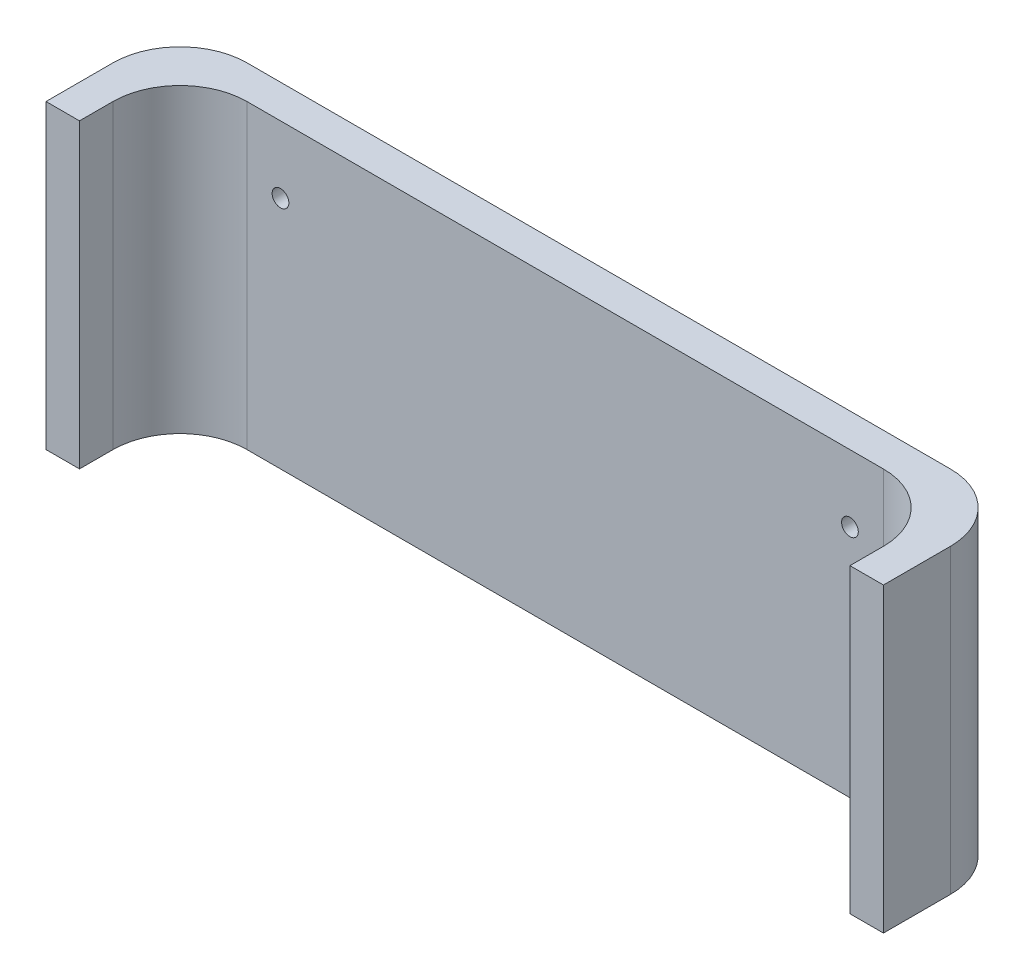
from build123d import *

# Parameters (mm, degrees)
SKETCH1_W           = 250
SKETCH1_H           = 250
SKETCH1_W_2         = 230
SKETCH1_H_2         = 230
BOSS_EXTRUDE1_DEPTH = 90
SKETCH2_W           = 200
SKETCH2_H           = 70
CUT_EXTRUDE1_DEPTH  = 50
FILLET1_R           = 20
SKETCH3_W           = 210
SKETCH3_H           = 90
CUT_EXTRUDE2_DEPTH  = 251
SKETCH4_R           = 2.5
CUT_EXTRUDE3_DEPTH  = 10


with BuildPart() as part:
    # Sketch1 → Boss-Extrude1 (new body)
    with BuildSketch(Plane(origin=(0, 0, 0), x_dir=(1, 0, 0), z_dir=(0, 1, 0))):
        Rectangle(SKETCH1_W, SKETCH1_H)
        Rectangle(SKETCH1_W_2, SKETCH1_H_2, mode=Mode.SUBTRACT)
    extrude(amount=BOSS_EXTRUDE1_DEPTH)

    # Sketch2 → Cut-Extrude1 (cut)
    with BuildSketch(Plane.XY.offset(125)):
        with Locations((0, 35)):
            Rectangle(SKETCH2_W, SKETCH2_H)
    extrude(amount=-CUT_EXTRUDE1_DEPTH, mode=Mode.SUBTRACT)

    # Fillet1
    fillet1_edges = [part.edges().sort_by_distance(p)[0] for p in [
        (-115, 45, 115),
        (115, 45, 115),
        (115, 45, -115),
        (-115, 45, -115),
        (-125, 45, 125),
        (125, 45, 125),
        (125, 45, -125),
        (-125, 45, -125),
    ]]
    fillet(fillet1_edges, radius=FILLET1_R)

    # Sketch3 → Cut-Extrude2 (cut, through all)
    with BuildSketch(Plane.ZY.offset(125)):
        with Locations((20, 45)):
            Rectangle(SKETCH3_W, SKETCH3_H)
    extrude(amount=-CUT_EXTRUDE2_DEPTH, mode=Mode.SUBTRACT)

    # Sketch4 → Cut-Extrude3 (cut)
    with BuildSketch(Plane(origin=(0, 0, -125), x_dir=(-1, 0, 0), z_dir=(0, 0, -1))):
        with Locations((85, 70)):
            Circle(SKETCH4_R)
        with Locations((-85, 70)):
            Circle(SKETCH4_R)
    extrude(amount=-CUT_EXTRUDE3_DEPTH, mode=Mode.SUBTRACT)


solid = part.part
